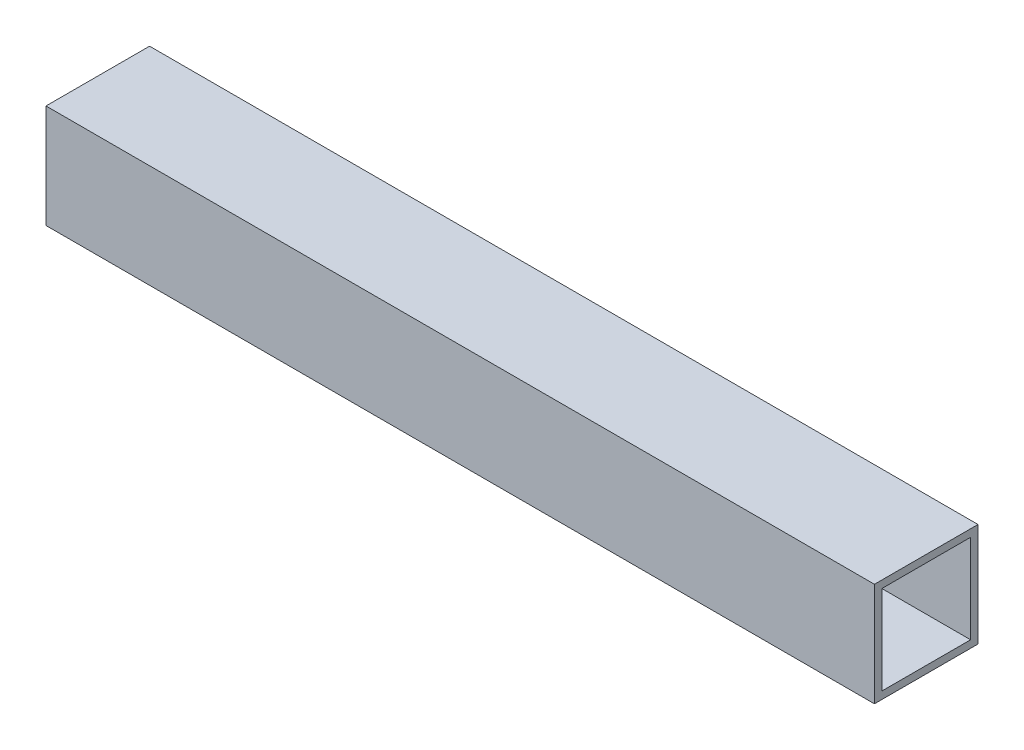
from build123d import *

# Parameters (mm, degrees)
SKETCH1_W           = 44.45
SKETCH1_H           = 44.45
SKETCH1_W_2         = 38.1
SKETCH1_H_2         = 38.1
BOSS_EXTRUDE1_DEPTH = 355.6


with BuildPart() as part:
    # Sketch1 → Boss-Extrude1 (new body)
    with BuildSketch(Plane(origin=(0, 0, 0), x_dir=(0, 0, -1), z_dir=(1, 0, 0))):
        with Locations((22.225, 22.225)):
            Rectangle(SKETCH1_W, SKETCH1_H)
        with Locations((22.225, 22.225)):
            Rectangle(SKETCH1_W_2, SKETCH1_H_2, mode=Mode.SUBTRACT)
    extrude(amount=BOSS_EXTRUDE1_DEPTH)


solid = part.part
